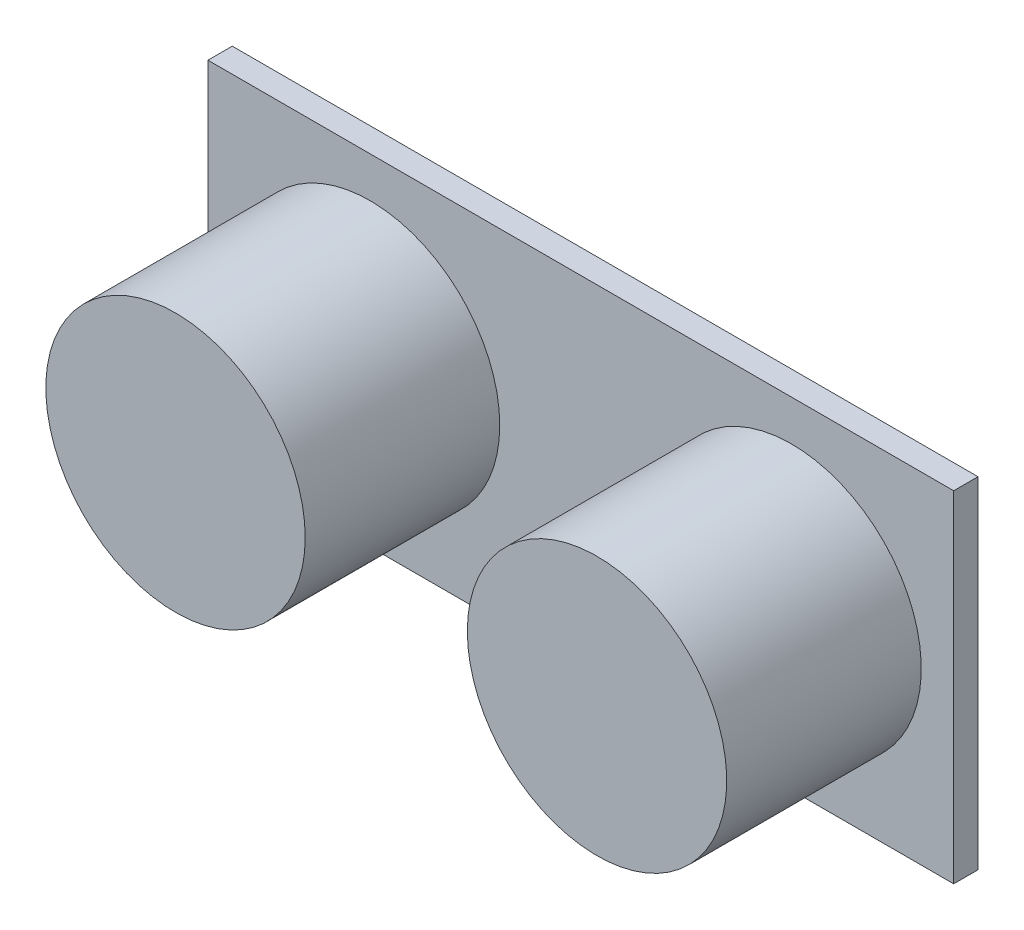
from build123d import *

# Parameters (mm, degrees)
SKETCH_1_W           = 46
SKETCH_1_H           = 21
EXTRUDE_1_DEPTH      = 1.5
SKETCH_2_R           = 8
EXTRUDE_2_DEPTH      = 12
SKETCH_3_W           = 10
SKETCH_3_H           = 3.04885902
EXTRUDE_3_DEPTH      = 1
EXTRUDE_3_DEPTH_BACK = 5


with BuildPart() as part:
    # 草图1 → 凸台-拉伸1 (new body)
    with BuildSketch(Plane.XY):
        with Locations((23, -10.5)):
            Rectangle(SKETCH_1_W, SKETCH_1_H)
    extrude(amount=EXTRUDE_1_DEPTH)

    # 草图2 → 凸台-拉伸2 (add)
    with BuildSketch(Plane.XY.offset(1.5)):
        with Locations((10, -10.5)):
            Circle(SKETCH_2_R)
        with Locations((36, -10.5)):
            Circle(SKETCH_2_R)
    extrude(amount=EXTRUDE_2_DEPTH)


with BuildPart() as body_2:
    # 草图3 → 凸台-拉伸3 (new body, two sides)
    with BuildSketch(Plane.XY.offset(1.5)) as extrude_3_sk:
        with Locations((23, -21)):
            Rectangle(SKETCH_3_W, SKETCH_3_H)
    extrude(amount=EXTRUDE_3_DEPTH)
    extrude(extrude_3_sk.sketch, amount=-EXTRUDE_3_DEPTH_BACK)


solid = Compound([part.part, body_2.part])
